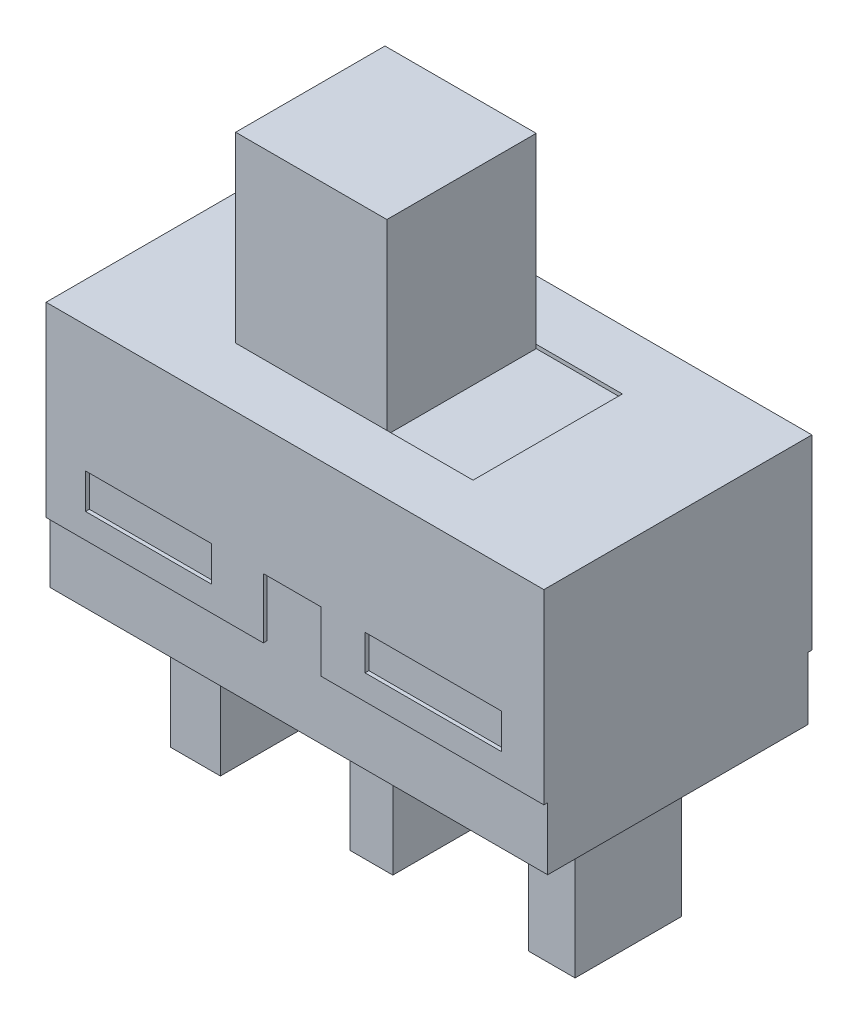
from build123d import *

# Parameters (mm, degrees)
SKETCH1_W                = 13
SKETCH1_H                = 6.8
BOSS_EXTRUDE1_DEPTH      = 6.4
SKETCH2_W                = 3.286897276
SKETCH2_H                = 0.917770019
SKETCH2_W_2              = 3.564362631
BOSS_EXTRUDE2_DEPTH      = 0.1
BOSS_EXTRUDE2_DEPTH_BACK = 6.9
SKETCH3_W                = 13
SKETCH3_H                = 7
SKETCH3_W_2              = 6.2
SKETCH3_H_2              = 3.9
BOSS_EXTRUDE3_DEPTH      = 0.1
SKETCH4_W                = 3.95
SKETCH4_H                = 3.9
BOSS_EXTRUDE4_DEPTH      = 4.87
SKETCH5_W                = 1.121207547
SKETCH5_H                = 2.774653545
SKETCH5_W_2              = 1.301952817
SKETCH5_H_2              = 2.838684011
SKETCH5_W_3              = 1.216578862
BOSS_EXTRUDE5_DEPTH      = 4


with BuildPart() as part:
    # Sketch1 → Boss-Extrude1 (new body)
    with BuildSketch(Plane(origin=(0, 0, 0), x_dir=(1, 0, 0), z_dir=(0, 1, 0))):
        with Locations((0.47556701, 2.025979381)):
            Rectangle(SKETCH1_W, SKETCH1_H)
    extrude(amount=BOSS_EXTRUDE1_DEPTH)

    # Sketch2 → Boss-Extrude2 (add, two sides)
    with BuildSketch(Plane.XY.offset(1.374020619)) as boss_extrude2_sk:
        Polygon((6.97556701, 6.4), (-6.02443299, 6.4), (-6.02443299, 1.631253573), (-0.351493181, 1.631253573), (-0.351493181, 3.2), (1.15322278, 3.2), (1.15322278, 1.631253573), (6.97556701, 1.631253573), align=None)
        with Locations((-3.350253358, 2.74111499)):
            Rectangle(SKETCH2_W, SKETCH2_H, mode=Mode.SUBTRACT)
        with Locations((4.087952491, 2.74111499)):
            Rectangle(SKETCH2_W_2, SKETCH2_H, mode=Mode.SUBTRACT)
    extrude(amount=BOSS_EXTRUDE2_DEPTH)
    extrude(boss_extrude2_sk.sketch, amount=-BOSS_EXTRUDE2_DEPTH_BACK)

    # Sketch3 → Boss-Extrude3 (add)
    with BuildSketch(Plane(origin=(0, 6.4, 0), x_dir=(1, 0, 0), z_dir=(0, 1, 0))):
        with Locations((0.47556701, 2.025979381)):
            Rectangle(SKETCH3_W, SKETCH3_H)
        with Locations((0.47556701, 2.025979381)):
            Rectangle(SKETCH3_W_2, SKETCH3_H_2, mode=Mode.SUBTRACT)
    extrude(amount=BOSS_EXTRUDE3_DEPTH)

    # Sketch4 → Boss-Extrude4 (add)
    with BuildSketch(Plane(origin=(0, 6.4, 0), x_dir=(1, 0, 0), z_dir=(0, 1, 0))):
        with Locations((-0.64943299, 2.025979381)):
            Rectangle(SKETCH4_W, SKETCH4_H)
    extrude(amount=BOSS_EXTRUDE4_DEPTH)

    # Sketch5 → Boss-Extrude5 (add)
    with BuildSketch(Plane.XZ):
        with Locations((0.400527608, -1.983292404)):
            Rectangle(SKETCH5_W, SKETCH5_H)
        with Locations((-4.182649421, -2.004635893)):
            Rectangle(SKETCH5_W_2, SKETCH5_H_2)
        with Locations((5.059081231, -2.036651126)):
            Rectangle(SKETCH5_W_3, SKETCH5_H)
    extrude(amount=BOSS_EXTRUDE5_DEPTH)


solid = part.part
